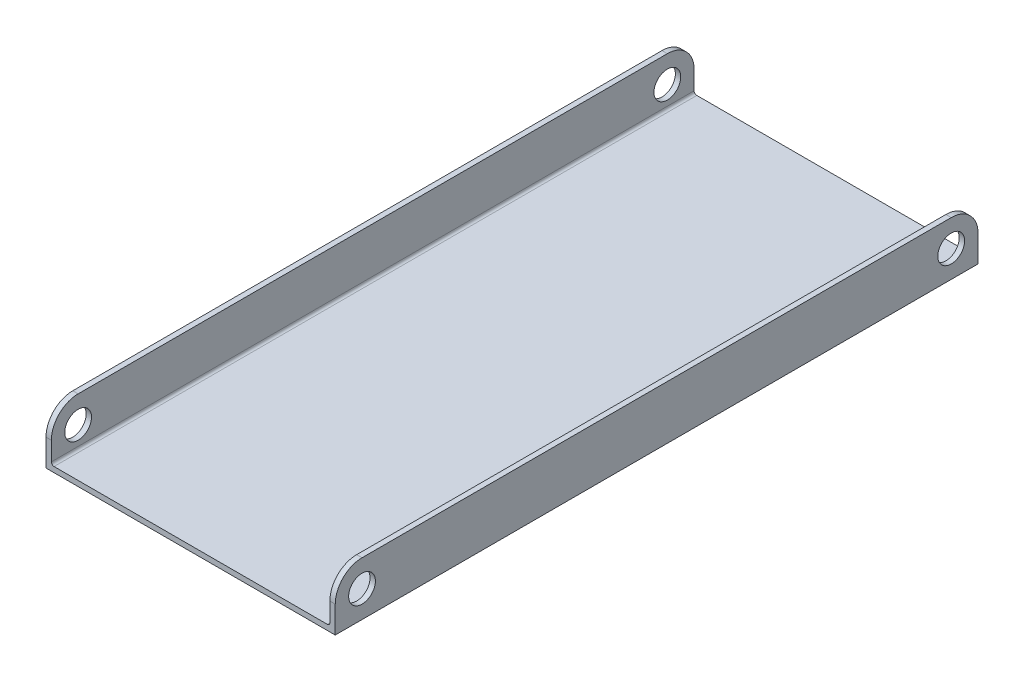
from build123d import *

# Parameters (mm, degrees)
BOSS_EXTRUDE1_DEPTH = 152.4
SKETCH2_R           = 3.175
CUT_EXTRUDE1_DEPTH  = 69.58
FILLET1_R           = 0.635


with BuildPart() as part:
    # Sketch1 → Boss-Extrude1 (new body)
    with BuildSketch(Plane.XY):
        Polygon((-34.29, 6.35), (-34.29, -6.35), (34.29, -6.35), (34.29, 6.35), (33.02, 6.35), (33.02, -5.08), (-33.02, -5.08), (-33.02, 6.35), align=None)
    extrude(amount=BOSS_EXTRUDE1_DEPTH)

    # Sketch2 → Cut-Extrude1 (cut, through all)
    with BuildSketch(Plane(origin=(34.29, 0, 0), x_dir=(0, 0, -1), z_dir=(1, 0, 0))):
        with Locations((-146.05, 0)):
            Circle(SKETCH2_R)
        with Locations((-6.35, 0)):
            Circle(SKETCH2_R)
        with BuildLine():
            Line((-152.4, 0), (-152.4, 6.35))
            Line((-152.4, 6.35), (-146.05, 6.35))
            ThreePointArc((-146.05, 6.35), (-150.540128061, 4.490128061), (-152.4, 0))
        make_face()
        with BuildLine():
            Line((0, 0), (0, 6.35))
            Line((0, 6.35), (-6.35, 6.35))
            ThreePointArc((-6.35, 6.35), (-1.859871939, 4.490128061), (0, 0))
        make_face()
    extrude(amount=-CUT_EXTRUDE1_DEPTH, mode=Mode.SUBTRACT)

    # Fillet1
    fillet1_edges = [part.edges().sort_by_distance(p)[0] for p in [
        (-33.02, -5.08, 76.2),
        (33.02, -5.08, 76.2),
    ]]
    fillet(fillet1_edges, radius=FILLET1_R)


solid = part.part
